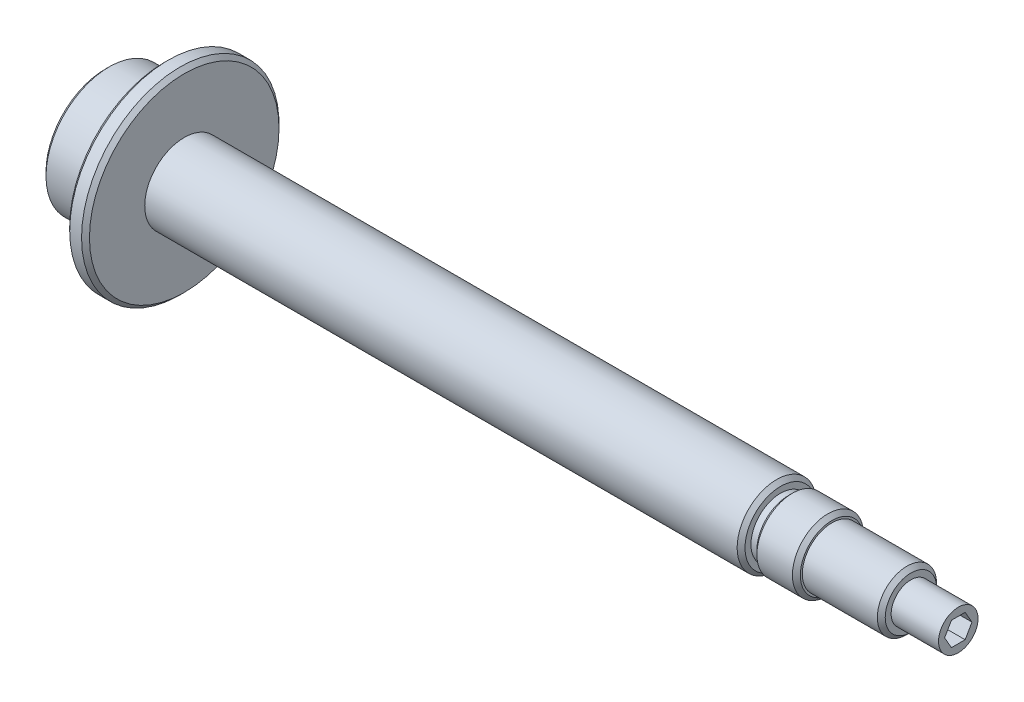
from build123d import *

# Parameters (mm, degrees)
HOLE_WIZARD_M101_D           = 8.5
HOLE_WIZARD_M101_DEPTH       = 24.946342369
HOLE_WIZARD_M101_CSINK_D     = 10.05
HOLE_WIZARD_M101_CSINK_ANGLE = 90
HOLE_WIZARD_M101_TIP         = 2.553657631
CUT_EXTRUDE_1_DEPTH          = 15


with BuildPart() as part:
    # Эскиз1 → Повернуть1 (revolve)
    with BuildSketch(Plane.XY):
        Polygon((0, 0), (0, 15), (1, 16), (15, 16), (15, 24), (16, 25), (19, 25), (20, 24), (20, 10), (170, 10), (171, 9), (171, 7.5), (173, 7.5), (173, 8), (174, 9), (183, 9), (184, 8), (184, 7.5), (203, 7.5), (204, 6.5), (204, 5), (216, 5), (216, 4), (216, 0), align=None)
    revolve(axis=Axis((0, 0, 0), (1, 0, 0)))

    # Отверстие обработанное метчиком M101
    with Locations(Plane.ZY):
        with Locations((0, 0)):
            CounterSinkHole(HOLE_WIZARD_M101_D / 2, HOLE_WIZARD_M101_CSINK_D / 2, depth=HOLE_WIZARD_M101_DEPTH, counter_sink_angle=HOLE_WIZARD_M101_CSINK_ANGLE)
            with Locations((0, 0, -(HOLE_WIZARD_M101_DEPTH + HOLE_WIZARD_M101_TIP / 2))):  # 118° drill point
                Cone(0, HOLE_WIZARD_M101_D / 2, HOLE_WIZARD_M101_TIP, mode=Mode.SUBTRACT)

    # Эскиз5 → Вырез-Вытянуть1 (cut)
    with BuildSketch(Plane(origin=(216, 0, 0), x_dir=(0, 0, -1), z_dir=(1, 0, 0))):
        Polygon((3.464101615, 0), (1.732050808, 3), (-1.732050808, 3), (-3.464101615, 0), (-1.732050808, -3), (1.732050808, -3), align=None)
    extrude(amount=-CUT_EXTRUDE_1_DEPTH, mode=Mode.SUBTRACT)


solid = part.part
